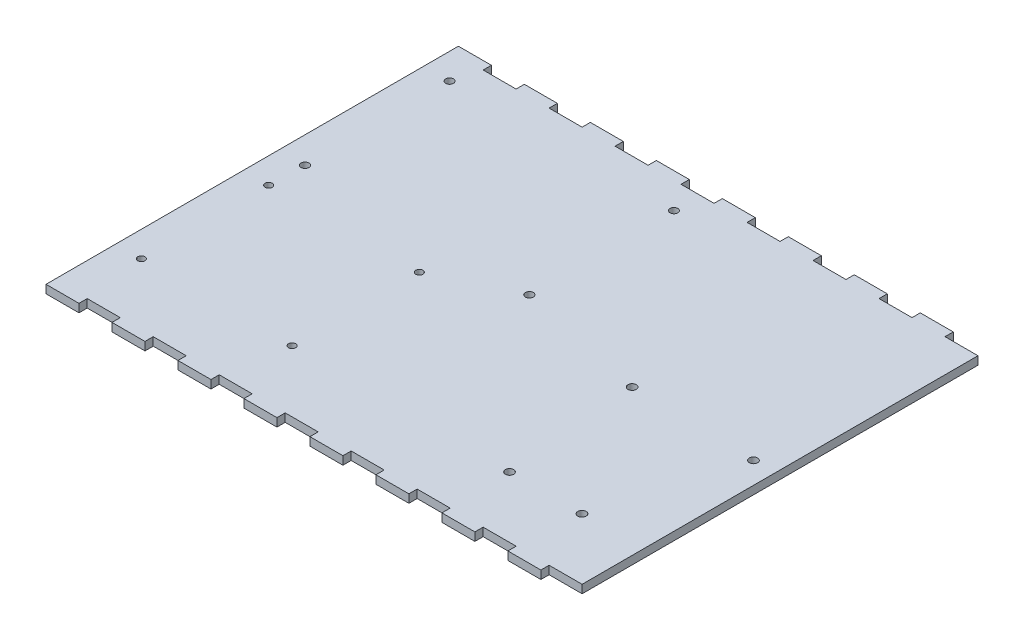
from build123d import *

# Parameters (mm, degrees)
SKETCH1_W               = 203.2
SKETCH1_H               = 152.4
BOSS_EXTRUDE1_DEPTH     = 3.175
SKETCH2_W               = 12.7
SKETCH2_H               = 3.175
BOSS_EXTRUDE2_DEPTH     = 3.175
BOSS_EXTRUDE2_2_DEPTH   = 3.175
BOSS_EXTRUDE2_3_DEPTH   = 3.175
BOSS_EXTRUDE2_4_DEPTH   = 3.175
BOSS_EXTRUDE2_5_DEPTH   = 3.175
BOSS_EXTRUDE2_6_DEPTH   = 3.175
BOSS_EXTRUDE2_7_DEPTH   = 3.175
BOSS_EXTRUDE2_8_DEPTH   = 3.175
BOSS_EXTRUDE2_9_DEPTH   = 3.175
BOSS_EXTRUDE2_10_DEPTH  = 3.175
BOSS_EXTRUDE2_11_DEPTH  = 3.175
BOSS_EXTRUDE2_12_DEPTH  = 3.175
BOSS_EXTRUDE2_13_DEPTH  = 3.175
BOSS_EXTRUDE2_14_DEPTH  = 3.175
BOSS_EXTRUDE2_15_DEPTH  = 3.175
BOSS_EXTRUDE2_16_DEPTH  = 3.175
SKETCH4_R               = 1.375
CUT_EXTRUDE1_DEPTH      = 294.475183832
SKETCH5_R               = 1.6
CUT_EXTRUDE2_DEPTH      = 317.962250237
CUT_EXTRUDE3_DEPTH      = 181.542007906
CUT_EXTRUDE3_DEPTH_BACK = 181.542007906
SKETCH10_R              = 1.535
SKETCH10_R_2            = 1.5


with BuildPart() as part:
    # Sketch1 → Boss-Extrude1 (new body)
    with BuildSketch(Plane(origin=(0, 0, 0), x_dir=(1, 0, 0), z_dir=(0, 1, 0))):
        with Locations((101.6, 76.2)):
            Rectangle(SKETCH1_W, SKETCH1_H)
    extrude(amount=BOSS_EXTRUDE1_DEPTH)

    # Sketch4 → Cut-Extrude1 (cut, through all)
    with BuildSketch(Plane(origin=(-65.618517222, 3.175, -114.528898402), x_dir=(1, 0, 0), z_dir=(0, 1, 0))):
        with Locations((75.468517222, -41.828898402)):
            Circle(SKETCH4_R)
        with Locations((75.468517222, -90.828898402)):
            Circle(SKETCH4_R)
        with Locations((133.468517222, -90.828898402)):
            Circle(SKETCH4_R)
        with Locations((133.468517222, -41.828898402)):
            Circle(SKETCH4_R)
    extrude(amount=-CUT_EXTRUDE1_DEPTH, mode=Mode.SUBTRACT)

    # Sketch5 → Cut-Extrude2 (cut, through all)
    with BuildSketch(Plane(origin=(-58.332709996, 3.175, -175.865858612), x_dir=(0, 0, 1), z_dir=(0, 1, 0))):
        with Locations((100.475405858, 205.398928035)):
            Circle(SKETCH5_R)
        with Locations((101.575405858, 253.198928035)):
            Circle(SKETCH5_R)
        with Locations((152.375405858, 210.098928035)):
            Circle(SKETCH5_R)
        with Locations((152.375405858, 237.998928035)):
            Circle(SKETCH5_R)
    extrude(amount=-CUT_EXTRUDE2_DEPTH, mode=Mode.SUBTRACT)

    # Sketch10 → Cut-Extrude3 (cut, two sides: drawn at the far end of the back side and taken through both)
    with BuildSketch(Plane(origin=(154.738240667, 3.175, -89.784200023), x_dir=(0, 0, -1), z_dir=(0, 1, 0)).offset(-CUT_EXTRUDE3_DEPTH_BACK)):
        with Locations((-3.423776116, 144.568240667)):
            Circle(SKETCH10_R)
        with Locations((52.455799977, 144.785900219)):
            Circle(SKETCH10_R_2)
        with Locations((-3.423776116, 58.208240667)):
            Circle(SKETCH10_R)
        with Locations((52.455799977, 58.425900219)):
            Circle(SKETCH10_R_2)
    extrude(amount=CUT_EXTRUDE3_DEPTH + CUT_EXTRUDE3_DEPTH_BACK, mode=Mode.SUBTRACT)


with BuildPart() as body_2:
    # Sketch2 → Boss-Extrude2 (new body)
    with BuildSketch(Plane(origin=(0, 3.175, 0), x_dir=(1, 0, 0), z_dir=(0, 1, 0))):
        with Locations((31.75, -1.5875)):
            Rectangle(SKETCH2_W, SKETCH2_H)
    extrude(amount=-BOSS_EXTRUDE2_DEPTH)


with BuildPart() as body_3:
    # Sketch2 → Boss-Extrude2 2 (new body)
    with BuildSketch(Plane(origin=(0, 3.175, 0), x_dir=(1, 0, 0), z_dir=(0, 1, 0))):
        with Locations((6.35, -1.5875)):
            Rectangle(SKETCH2_W, SKETCH2_H)
    extrude(amount=-BOSS_EXTRUDE2_2_DEPTH)


with BuildPart() as body_4:
    # Sketch2 → Boss-Extrude2 3 (new body)
    with BuildSketch(Plane(origin=(0, 3.175, 0), x_dir=(1, 0, 0), z_dir=(0, 1, 0))):
        with Locations((57.15, -1.5875)):
            Rectangle(SKETCH2_W, SKETCH2_H)
    extrude(amount=-BOSS_EXTRUDE2_3_DEPTH)


with BuildPart() as body_5:
    # Sketch2 → Boss-Extrude2 4 (new body)
    with BuildSketch(Plane(origin=(0, 3.175, 0), x_dir=(1, 0, 0), z_dir=(0, 1, 0))):
        with Locations((82.55, -1.5875)):
            Rectangle(SKETCH2_W, SKETCH2_H)
    extrude(amount=-BOSS_EXTRUDE2_4_DEPTH)


with BuildPart() as body_6:
    # Sketch2 → Boss-Extrude2 5 (new body)
    with BuildSketch(Plane(origin=(0, 3.175, 0), x_dir=(1, 0, 0), z_dir=(0, 1, 0))):
        with Locations((107.95, -1.5875)):
            Rectangle(SKETCH2_W, SKETCH2_H)
    extrude(amount=-BOSS_EXTRUDE2_5_DEPTH)


with BuildPart() as body_7:
    # Sketch2 → Boss-Extrude2 6 (new body)
    with BuildSketch(Plane(origin=(0, 3.175, 0), x_dir=(1, 0, 0), z_dir=(0, 1, 0))):
        with Locations((133.35, -1.5875)):
            Rectangle(SKETCH2_W, SKETCH2_H)
    extrude(amount=-BOSS_EXTRUDE2_6_DEPTH)


with BuildPart() as body_8:
    # Sketch2 → Boss-Extrude2 7 (new body)
    with BuildSketch(Plane(origin=(0, 3.175, 0), x_dir=(1, 0, 0), z_dir=(0, 1, 0))):
        with Locations((158.75, -1.5875)):
            Rectangle(SKETCH2_W, SKETCH2_H)
    extrude(amount=-BOSS_EXTRUDE2_7_DEPTH)


with BuildPart() as body_9:
    # Sketch2 → Boss-Extrude2 8 (new body)
    with BuildSketch(Plane(origin=(0, 3.175, 0), x_dir=(1, 0, 0), z_dir=(0, 1, 0))):
        with Locations((184.15, -1.5875)):
            Rectangle(SKETCH2_W, SKETCH2_H)
    extrude(amount=-BOSS_EXTRUDE2_8_DEPTH)


with BuildPart() as body_10:
    # Sketch2 → Boss-Extrude2 9 (new body)
    with BuildSketch(Plane(origin=(0, 3.175, 0), x_dir=(1, 0, 0), z_dir=(0, 1, 0))):
        with Locations((184.15, 153.9875)):
            Rectangle(SKETCH2_W, SKETCH2_H)
    extrude(amount=-BOSS_EXTRUDE2_9_DEPTH)


with BuildPart() as body_11:
    # Sketch2 → Boss-Extrude2 10 (new body)
    with BuildSketch(Plane(origin=(0, 3.175, 0), x_dir=(1, 0, 0), z_dir=(0, 1, 0))):
        with Locations((158.75, 153.9875)):
            Rectangle(SKETCH2_W, SKETCH2_H)
    extrude(amount=-BOSS_EXTRUDE2_10_DEPTH)


with BuildPart() as body_12:
    # Sketch2 → Boss-Extrude2 11 (new body)
    with BuildSketch(Plane(origin=(0, 3.175, 0), x_dir=(1, 0, 0), z_dir=(0, 1, 0))):
        with Locations((133.35, 153.9875)):
            Rectangle(SKETCH2_W, SKETCH2_H)
    extrude(amount=-BOSS_EXTRUDE2_11_DEPTH)


with BuildPart() as body_13:
    # Sketch2 → Boss-Extrude2 12 (new body)
    with BuildSketch(Plane(origin=(0, 3.175, 0), x_dir=(1, 0, 0), z_dir=(0, 1, 0))):
        with Locations((107.95, 153.9875)):
            Rectangle(SKETCH2_W, SKETCH2_H)
    extrude(amount=-BOSS_EXTRUDE2_12_DEPTH)


with BuildPart() as body_14:
    # Sketch2 → Boss-Extrude2 13 (new body)
    with BuildSketch(Plane(origin=(0, 3.175, 0), x_dir=(1, 0, 0), z_dir=(0, 1, 0))):
        with Locations((82.55, 153.9875)):
            Rectangle(SKETCH2_W, SKETCH2_H)
    extrude(amount=-BOSS_EXTRUDE2_13_DEPTH)


with BuildPart() as body_15:
    # Sketch2 → Boss-Extrude2 14 (new body)
    with BuildSketch(Plane(origin=(0, 3.175, 0), x_dir=(1, 0, 0), z_dir=(0, 1, 0))):
        with Locations((57.15, 153.9875)):
            Rectangle(SKETCH2_W, SKETCH2_H)
    extrude(amount=-BOSS_EXTRUDE2_14_DEPTH)


with BuildPart() as body_16:
    # Sketch2 → Boss-Extrude2 15 (new body)
    with BuildSketch(Plane(origin=(0, 3.175, 0), x_dir=(1, 0, 0), z_dir=(0, 1, 0))):
        with Locations((31.75, 153.9875)):
            Rectangle(SKETCH2_W, SKETCH2_H)
    extrude(amount=-BOSS_EXTRUDE2_15_DEPTH)


with BuildPart() as body_17:
    # Sketch2 → Boss-Extrude2 16 (new body)
    with BuildSketch(Plane(origin=(0, 3.175, 0), x_dir=(1, 0, 0), z_dir=(0, 1, 0))):
        with Locations((6.35, 153.9875)):
            Rectangle(SKETCH2_W, SKETCH2_H)
    extrude(amount=-BOSS_EXTRUDE2_16_DEPTH)


with BuildPart() as body_3_1:
    add(body_3.part)

    # Combine1: union body 4, body 6, body 8, body 10, body 12, body 14, body 16, body 17, part, body 2, body 5, body 7, body 9, body 11, body 13, body 15
    add(body_4.part)
    add(body_6.part)
    add(body_8.part)
    add(body_10.part)
    add(body_12.part)
    add(body_14.part)
    add(body_16.part)
    add(body_17.part)
    add(part.part)
    add(body_2.part)
    add(body_5.part)
    add(body_7.part)
    add(body_9.part)
    add(body_11.part)
    add(body_13.part)
    add(body_15.part)


solid = body_3_1.part
